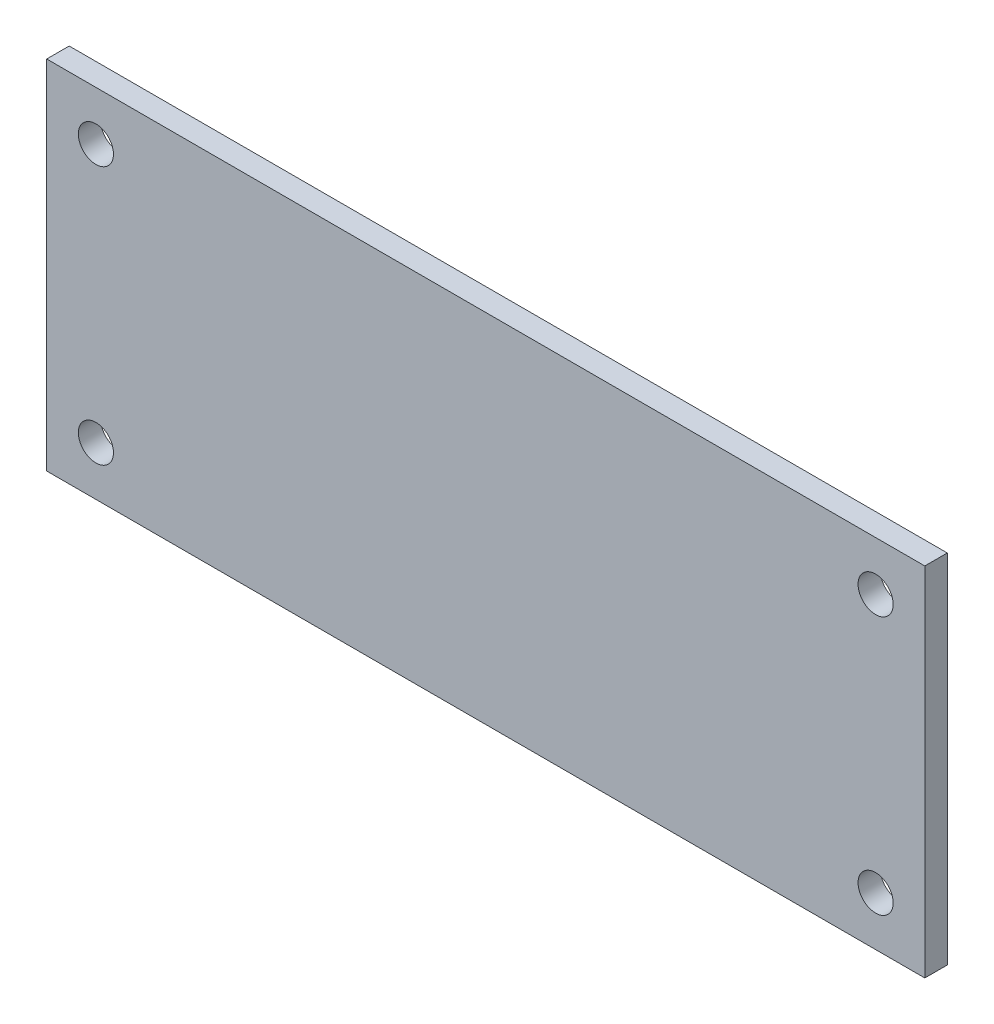
from build123d import *

# Parameters (mm, degrees)
SKETCH1_W           = 62.5
SKETCH1_H           = 25.4
SKETCH1_R           = 1.25
BOSS_EXTRUDE1_DEPTH = 1.6


with BuildPart() as part:
    # Sketch1 → Boss-Extrude1 (new body)
    with BuildSketch(Plane.XY):
        Rectangle(SKETCH1_W, SKETCH1_H)
        with Locations((-27.75, 9.2)):
            Circle(SKETCH1_R, mode=Mode.SUBTRACT)
        with Locations((27.75, 9.2)):
            Circle(SKETCH1_R, mode=Mode.SUBTRACT)
        with Locations((27.75, -9.2)):
            Circle(SKETCH1_R, mode=Mode.SUBTRACT)
        with Locations((-27.75, -9.2)):
            Circle(SKETCH1_R, mode=Mode.SUBTRACT)
    extrude(amount=BOSS_EXTRUDE1_DEPTH)


solid = part.part
